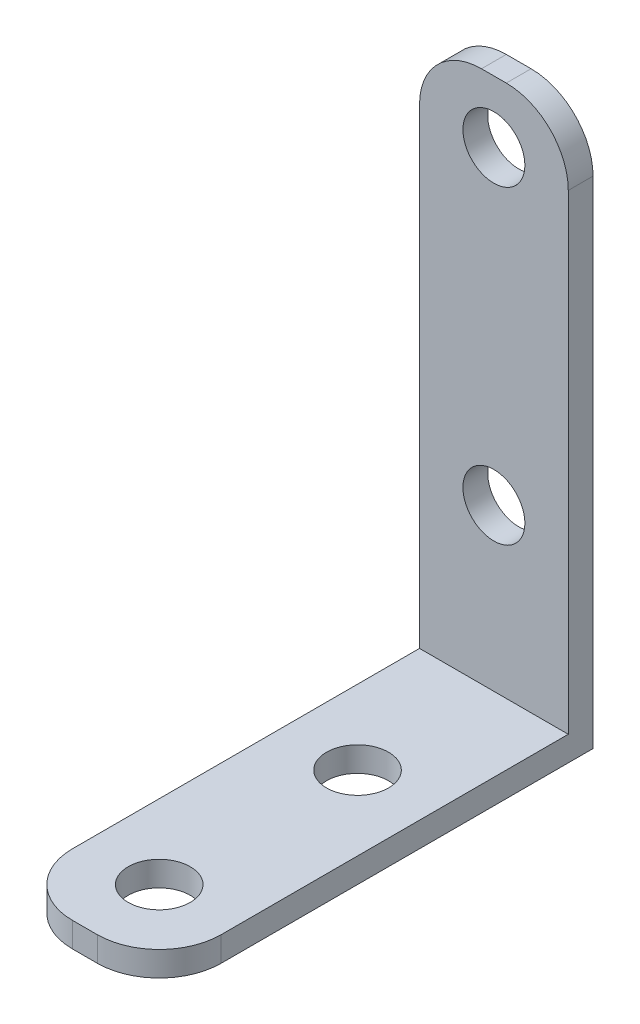
from build123d import *

# Parameters (mm, degrees)
SKETCH1_W           = 12
SKETCH1_H           = 45
SKETCH1_R           = 2.5
BOSS_EXTRUDE1_DEPTH = 2
FILLET3_R           = 5
SKETCH2_W           = 12
SKETCH2_H           = 2
BOSS_EXTRUDE2_DEPTH = 33
SKETCH3_R           = 2.5
CUT_EXTRUDE1_DEPTH  = 33
FILLET4_R           = 5


with BuildPart() as part:
    # Sketch1 → Boss-Extrude1 (new body)
    with BuildSketch(Plane.XY):
        Rectangle(SKETCH1_W, SKETCH1_H)
        with Locations((0, -7.5)):
            Circle(SKETCH1_R, mode=Mode.SUBTRACT)
        with Locations((0, 17.5)):
            Circle(SKETCH1_R, mode=Mode.SUBTRACT)
    extrude(amount=BOSS_EXTRUDE1_DEPTH)

    # Fillet3
    fillet3_edges = [part.edges().sort_by_distance(p)[0] for p in [
        (-6, 22.5, 1),
        (6, 22.5, 1),
    ]]
    fillet(fillet3_edges, radius=FILLET3_R)

    # Sketch2 → Boss-Extrude2 (add)
    with BuildSketch(Plane.XY.offset(2)):
        with Locations((0, -21.5)):
            Rectangle(SKETCH2_W, SKETCH2_H)
    extrude(amount=BOSS_EXTRUDE2_DEPTH)

    # Sketch3 → Cut-Extrude1 (cut)
    with BuildSketch(Plane(origin=(0, -20.5, 0), x_dir=(1, 0, 0), z_dir=(0, 1, 0))):
        with Locations((0, -13)):
            Circle(SKETCH3_R)
        with Locations((0, -29)):
            Circle(SKETCH3_R)
    extrude(amount=-CUT_EXTRUDE1_DEPTH, mode=Mode.SUBTRACT)

    # Fillet4
    fillet4_edges = [part.edges().sort_by_distance(p)[0] for p in [
        (-6, -21.5, 35),
        (6, -21.5, 35),
    ]]
    fillet(fillet4_edges, radius=FILLET4_R)


solid = part.part
